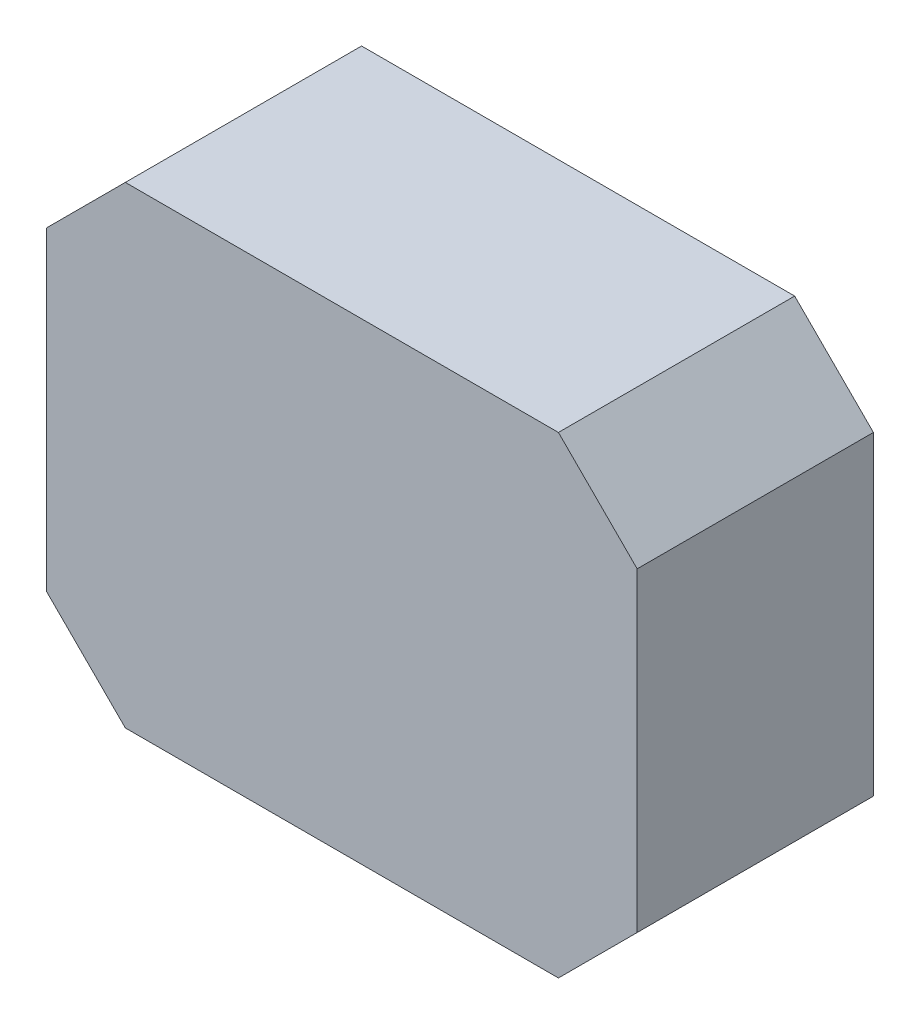
from build123d import *

# Parameters (mm, degrees)
SKETCH1_W           = 150
SKETCH1_H           = 120
BOSS_EXTRUDE1_DEPTH = 30
CHAMFER1_SIZE       = 20


with BuildPart() as part:
    # Sketch1 → Boss-Extrude1 (new body, symmetric)
    with BuildSketch(Plane.XY):
        with Locations((75, 60)):
            Rectangle(SKETCH1_W, SKETCH1_H)
    extrude(amount=BOSS_EXTRUDE1_DEPTH, both=True)

    # Chamfer1
    chamfer1_edges = [part.edges().sort_by_distance(p)[0] for p in [
        (0, 120, 0),
        (150, 120, 0),
        (150, 0, 0),
        (0, 0, 0),
    ]]
    chamfer(chamfer1_edges, length=CHAMFER1_SIZE)


solid = part.part
